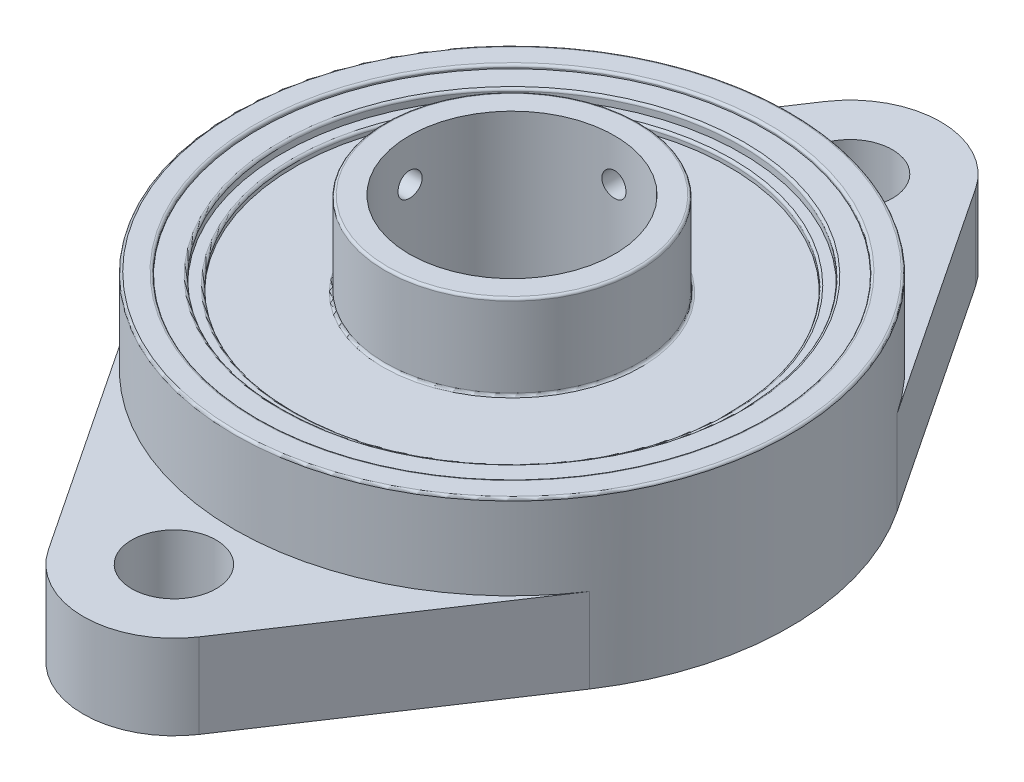
from build123d import *

# Parameters (mm, degrees)
SKETCH1_R             = 3.4999999999999987
SKETCH1_R_2           = 20.999999999999996
EXTRUDE_A1_DEPTH      = 7
SKETCH1_3_R           = 20.999999999999996
EXTRUDE_A_DEPTH       = 14
SKETCH1_4_R           = 10.5
SKETCH1_4_R_2         = 8.5
EXTRUDE_A0_DEPTH      = 19.5
BEARING_START         = 2
SKETCH1_7_R           = 18.999999999999996
SKETCH1_7_R_2         = 17.999999999999996
BEARING_OUTER_D_DEPTH = 11
BOSS_EXTRUDE6_START   = 1.2
SKETCH1_8_R           = 20.999999999999996
SKETCH1_8_R_2         = 18.999999999999996
BOSS_EXTRUDE6_DEPTH   = 12.5
BOSS_EXTRUDE7_START   = 1.5
SKETCH1_9_R           = 17.999999999999996
SKETCH1_9_R_2         = 10.5
BOSS_EXTRUDE7_DEPTH   = 11
CUT_EXTRUDE1_REACH    = 48.578
SKETCH2_R             = 1.0000000000000013
CUT_EXTRUDE2_REACH    = 48.578
SKETCH3_R             = 1.000000000000002
FILLET1_R             = 0.2
FILLET2_R             = 0.2


with BuildPart() as part:
    # Sketch1 → Extrude A1 (new body)
    with BuildSketch(Plane(origin=(0, 0, 0), x_dir=(1, 0, 0), z_dir=(0, 1, 0))):
        with BuildLine():
            Line((6.246012758764824, -32.15178571428571), (19.15443912687881, -12.732142857142854))
            ThreePointArc((19.154439126878817, -12.732142857142858), (23, 0), (19.154439126878817, 12.732142857142858))
            Line((19.15443912687881, 12.732142857142854), (6.246012758764824, 32.15178571428571))
            ThreePointArc((6.246012758764825, 32.15178571428571), (6.7e-16, 35.49999999999999), (-6.246012758764825, 32.15178571428571))
            Line((-6.246012758764824, 32.15178571428571), (-19.15443912687881, 12.732142857142854))
            ThreePointArc((-19.154439126878813, 12.732142857142863), (-23, 2.82e-15), (-19.154439126878817, -12.732142857142858))
            Line((-19.15443912687881, -12.732142857142854), (-6.246012758764824, -32.15178571428571))
            ThreePointArc((-6.246012758764825, -32.15178571428571), (-2.2e-16, -35.49999999999999), (6.246012758764825, -32.15178571428571))
        make_face()
        with Locations((0, -28)):
            Circle(SKETCH1_R, mode=Mode.SUBTRACT)
        Circle(SKETCH1_R_2, mode=Mode.SUBTRACT)
        with Locations((0, 28)):
            Circle(SKETCH1_R, mode=Mode.SUBTRACT)
    extrude(amount=EXTRUDE_A1_DEPTH)

    # Sketch1_3 → Extrude A (add)
    with BuildSketch(Plane(origin=(0, 0, 0), x_dir=(1, 0, 0), z_dir=(0, 1, 0))):
        with BuildLine():
            ThreePointArc((-19.154439126878817, -12.732142857142858), (-4.23e-15, -23), (19.154439126878817, -12.732142857142856))
            ThreePointArc((19.154439126878817, -12.732142857142856), (22.017630434701786, -6.650109024737387), (23, -5.63e-15))
            ThreePointArc((23, 0), (22.017630434701786, 6.650109024737384), (19.154439126878817, 12.732142857142858))
            ThreePointArc((19.154439126878817, 12.732142857142858), (1.41e-15, 23), (-19.154439126878813, 12.732142857142863))
            ThreePointArc((-19.154439126878813, 12.732142857142863), (-23, 2.82e-15), (-19.154439126878817, -12.732142857142858))
        make_face()
        Circle(SKETCH1_3_R, mode=Mode.SUBTRACT)
    extrude(amount=EXTRUDE_A_DEPTH)



with BuildPart() as body_2:
    # Sketch1_4 → Extrude A0 (new body)
    with BuildSketch(Plane(origin=(0, 0, 0), x_dir=(1, 0, 0), z_dir=(0, 1, 0))):
        Circle(SKETCH1_4_R)
        Circle(SKETCH1_4_R_2, mode=Mode.SUBTRACT)
    extrude(amount=EXTRUDE_A0_DEPTH)


with BuildPart() as body_3:
    # Sketch1_7 → Bearing outer d (new body)
    with BuildSketch(Plane(origin=(0, 0, 0), x_dir=(1, 0, 0), z_dir=(0, 1, 0)).offset(BEARING_START)):
        Circle(SKETCH1_7_R)
        Circle(SKETCH1_7_R_2, mode=Mode.SUBTRACT)
    extrude(amount=BEARING_OUTER_D_DEPTH)


with BuildPart() as part_1:
    add(part.part)

    add(body_3.part)  # Boss-Extrude6 merges body 3
    # Sketch1_8 → Boss-Extrude6 (add)
    with BuildSketch(Plane(origin=(0, 0, 0), x_dir=(1, 0, 0), z_dir=(0, 1, 0)).offset(BOSS_EXTRUDE6_START)):
        Circle(SKETCH1_8_R)
        Circle(SKETCH1_8_R_2, mode=Mode.SUBTRACT)
    extrude(amount=BOSS_EXTRUDE6_DEPTH)


    add(body_2.part)  # Boss-Extrude7 merges body 2
    # Sketch1_9 → Boss-Extrude7 (add)
    with BuildSketch(Plane(origin=(0, 0, 0), x_dir=(1, 0, 0), z_dir=(0, 1, 0)).offset(BOSS_EXTRUDE7_START)):
        Circle(SKETCH1_9_R)
        Circle(SKETCH1_9_R_2, mode=Mode.SUBTRACT)
    extrude(amount=BOSS_EXTRUDE7_DEPTH)

    # Sketch2 → Cut-Extrude1 (cut, up to next)
    with BuildSketch(Plane(origin=(0, 0, 0), x_dir=(0, 0, -1), z_dir=(1, 0, 0)), mode=Mode.PRIVATE) as cut_extrude1_sk1:
        with Locations((-8.7e-16, 16)):
            Circle(SKETCH2_R)
    cut_extrude1_tool1 = extrude(cut_extrude1_sk1.sketch, amount=-CUT_EXTRUDE1_REACH, mode=Mode.PRIVATE) & part_1.part
    add(cut_extrude1_tool1.solids().sort_by_distance((0, 16, 0))[0], mode=Mode.SUBTRACT)

    # Sketch3 → Cut-Extrude2 (cut, up to next)
    with BuildSketch(Plane.XY, mode=Mode.PRIVATE) as cut_extrude2_sk1:
        with Locations((0, 16)):
            Circle(SKETCH3_R)
    cut_extrude2_tool1 = extrude(cut_extrude2_sk1.sketch, amount=-CUT_EXTRUDE2_REACH, mode=Mode.PRIVATE) & part_1.part
    add(cut_extrude2_tool1.solids().sort_by_distance((0, 16, 0))[0], mode=Mode.SUBTRACT)

    # Fillet1
    fillet1_edges = [part_1.edges().sort_by_distance(p)[0] for p in [
        (-17.999999999999996, 13, -2.2e-15),
    ]]
    fillet(fillet1_edges, radius=FILLET1_R)

    # Fillet2
    fillet2_edges = [part_1.edges().sort_by_distance(p)[0] for p in [
        (-10.5, 19.5, -1.29e-15),
        (-10.5, 12.5, -1.29e-15),
        (-19.154439126878817, 14, -12.732142857142891),
        (-20.999999999999996, 14, -2.57e-15),
        (-18.999999999999996, 13.7, -2.33e-15),
    ]]
    fillet(fillet2_edges, radius=FILLET2_R)


solid = part_1.part
